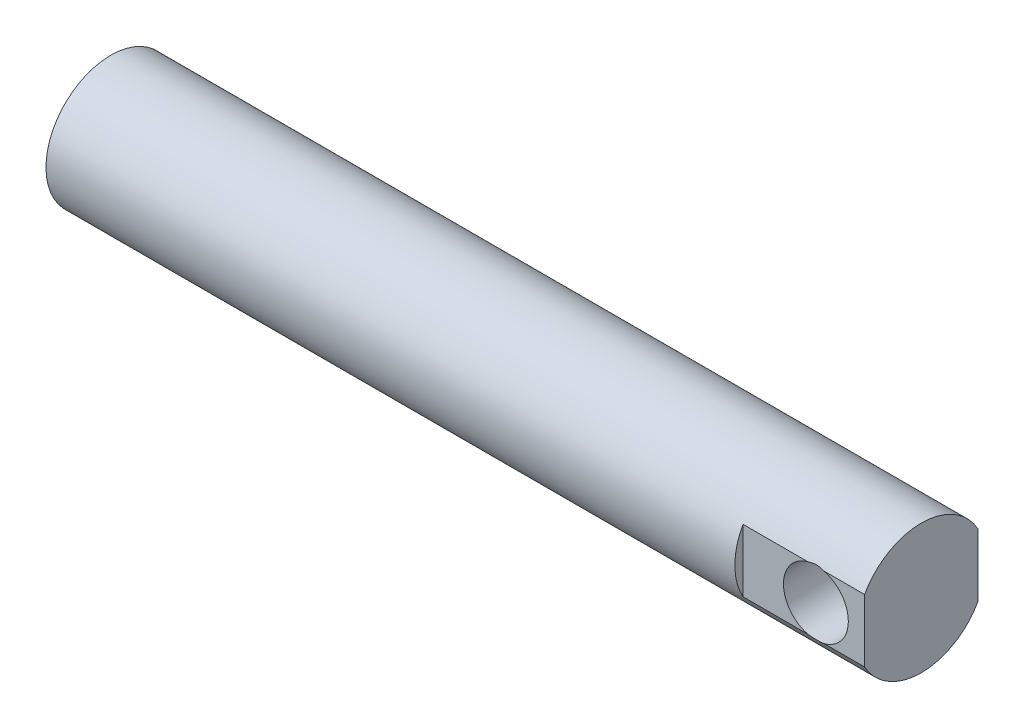
from build123d import *

# Parameters (mm, degrees)
SKETCH2_R           = 25.4
BOSS_EXTRUDE1_DEPTH = 158.75
CUT_EXTRUDE1_DEPTH  = 47.625
SKETCH4_R           = 12.7
CUT_EXTRUDE2_DEPTH  = 48.625


with BuildPart() as part:
    # Sketch2 → Boss-Extrude1 (new body, symmetric)
    with BuildSketch(Plane(origin=(0, 0, 0), x_dir=(0, 0, -1), z_dir=(1, 0, 0))):
        Circle(SKETCH2_R)
    extrude(amount=BOSS_EXTRUDE1_DEPTH, both=True)

    # Sketch3 → Cut-Extrude1 (cut)
    with BuildSketch(Plane(origin=(158.75, 0, 0), x_dir=(0, 0, -1), z_dir=(1, 0, 0))):
        with BuildLine():
            Line((-22.225, 12.296722124), (-22.225, -12.296722124))
            ThreePointArc((-22.225, -12.296722124), (-25.4, 0), (-22.225, 12.296722124))
        make_face()
        with BuildLine():
            Line((22.225, 12.296722124), (22.225, -12.296722124))
            ThreePointArc((22.225, -12.296722124), (25.4, 0), (22.225, 12.296722124))
        make_face()
    extrude(amount=-CUT_EXTRUDE1_DEPTH, mode=Mode.SUBTRACT)

    # Sketch4 → Cut-Extrude2 (cut, through all)
    with BuildSketch(Plane.XY.offset(22.225)):
        with Locations((139.7, 0)):
            Circle(SKETCH4_R)
    extrude(amount=-CUT_EXTRUDE2_DEPTH, mode=Mode.SUBTRACT)


solid = part.part
